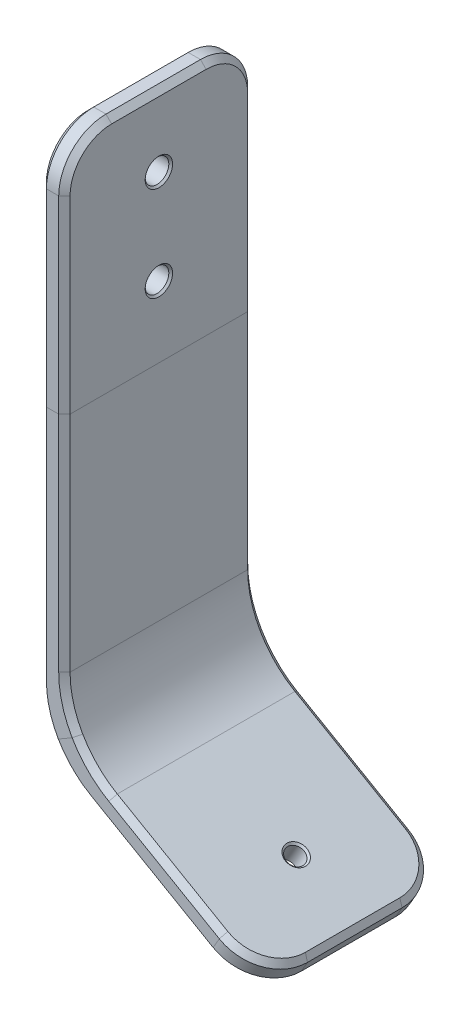
from build123d import *

# Parameters (mm, degrees)
SKETCH2_W                       = 3.175
SKETCH2_H                       = 25.4
F_1_8_0_125_DIAMETER_HOLE1_D    = 3.175
F_3_32_0_09375_DIAMETER_HOLE2_D = 2.38125
FILLET1_R                       = 12.7
FILLET2_R                       = 6.35
CHAMFER3_SIZE                   = 0.762
CHAMFER2_SIZE                   = 0.254


with BuildPart() as part:
    # Sweep1: sweep along a path in Sketch1
    with BuildLine(Plane.XY) as sweep1_path:
        Line((0, 0), (0, -31.75))
        Line((0, -31.75), (0, -70.0334134))
        Line((0, -70.0334134), (27.49630657, -85.9084134))
    # Sketch2 → Sweep1 (sweep)
    with BuildSketch(Plane(origin=(0, 0, 0), x_dir=(1, 0, 0), z_dir=(0, 1, 0))):
        Rectangle(SKETCH2_W, SKETCH2_H)
    sweep(path=sweep1_path.line, transition=Transition.RIGHT)

    # 1/8 (0.125) Diameter Hole1 (through all)
    with Locations(Plane(origin=(1.5875, 0, 0), x_dir=(0, 0, -1), z_dir=(1, 0, 0))):
        with Locations((0, -9.525), (0, -22.225)):
            Hole(F_1_8_0_125_DIAMETER_HOLE1_D / 2)

    # 3/32 (0.09375) Diameter Hole2 (through all)
    with Locations(Plane(origin=(-29.531607559, -51.150244721, 0), x_dir=(0.866025404, -0.5, 0), z_dir=(0.5, 0.866025404, 0))):
        with Locations((57.2417067, 0)):
            Hole(F_3_32_0_09375_DIAMETER_HOLE2_D / 2)

    # Fillet1
    fillet1_edges = [part.edges().sort_by_distance(p)[0] for p in [
        (1.5875, -69.116869848, 0),
        (-1.5875, -70.949956952, 0),
    ]]
    fillet(fillet1_edges, radius=FILLET1_R)

    # Fillet2
    fillet2_edges = [part.edges().sort_by_distance(p)[0] for p in [
        (27.49630657, -85.9084134, -12.7),
        (27.49630657, -85.9084134, 12.7),
        (0, 0, -12.7),
        (0, 0, 12.7),
    ]]
    fillet(fillet2_edges, radius=FILLET2_R)

    # Chamfer3
    chamfer3_edges = [part.edges().sort_by_distance(p)[0] for p in [
        (12.982897628, -79.362179945, -12.7),
        (12.982897628, -79.362179945, 12.7),
        (15.364147628, -77.070821064, -12.7),
        (0.113977372, -69.967608534, -12.7),
        (0.113977372, -69.967608534, -12.7),
        (0.113977372, -69.967608534, 12.7),
        (15.364147628, -77.070821064, 12.7),
        (0.113977372, -69.967608534, 12.7),
        (3.288977372, -68.134521429, 12.7),
        (3.288977372, -68.134521429, 12.7),
        (3.288977372, -68.134521429, -12.7),
        (3.288977372, -68.134521429, -12.7),
        (1.5875, -34.067260714, 12.7),
        (1.5875, -34.067260714, -12.7),
        (-1.5875, -34.983804267, -12.7),
        (-1.5875, -34.983804267, 12.7),
        (26.70255657, -87.283228729, 0),
        (25.091860223, -86.353292759, 10.840128061),
        (25.091860223, -86.353292759, -10.840128061),
        (28.29005657, -84.533598071, 0),
        (26.679360223, -83.603662102, 10.840128061),
        (26.679360223, -83.603662102, -10.840128061),
        (1.5875, 0, 0),
        (-1.5875, 0, 0),
        (-1.5875, -34.983804267, 12.7),
        (-1.5875, -34.983804267, -12.7),
        (-1.5875, -1.859871939, 10.840128061),
        (-1.5875, -1.859871939, -10.840128061),
        (1.5875, -34.067260714, -12.7),
        (1.5875, -34.067260714, 12.7),
        (1.5875, -1.859871939, 10.840128061),
        (1.5875, -1.859871939, -10.840128061),
    ]]
    chamfer(chamfer3_edges, length=CHAMFER3_SIZE)

    # Chamfer2
    chamfer2_edges = [part.edges().sort_by_distance(p)[0] for p in [
        (1.5875, -22.225, -1.5875),
        (-1.5875, -22.225, -1.5875),
        (1.5875, -9.525, -1.5875),
        (-1.5875, -9.525, -1.5875),
        (19.484776095, -83.116041229, 0),
        (21.072276095, -80.366410571, 0),
    ]]
    chamfer(chamfer2_edges, length=CHAMFER2_SIZE)


solid = part.part
